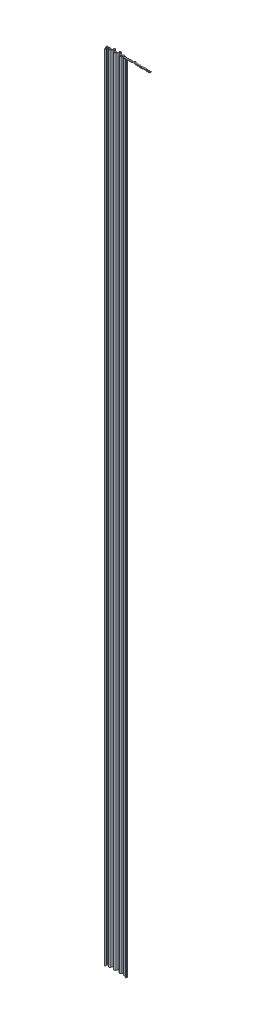
from build123d import *

# Parameters (mm, degrees)
BOSS_EXTRUDE1_DEPTH    = 2.54
SKETCH1_R              = 3.81
BOSS_EXTRUDE1_2_DEPTH  = 2.54
BOSS_EXTRUDE1_3_DEPTH  = 2.54
SKETCH1_R_2            = 3.745422698
BOSS_EXTRUDE1_4_DEPTH  = 2.54
BOSS_EXTRUDE1_5_DEPTH  = 2.54
BOSS_EXTRUDE1_6_DEPTH  = 2.54
SKETCH1_R_3            = 3.74542269
BOSS_EXTRUDE1_7_DEPTH  = 2.54
BOSS_EXTRUDE1_8_DEPTH  = 2.54
BOSS_EXTRUDE1_9_DEPTH  = 2.54
BOSS_EXTRUDE1_10_DEPTH = 2.54
BOSS_EXTRUDE1_11_DEPTH = 2.54
BOSS_EXTRUDE1_12_DEPTH = 2.54
SKETCH1_R_4            = 3.80999999
BOSS_EXTRUDE1_13_DEPTH = 2.54
BOSS_EXTRUDE1_14_DEPTH = 2.54
SKETCH1_R_5            = 3.809999995
BOSS_EXTRUDE1_15_DEPTH = 2.54
BOSS_EXTRUDE1_16_DEPTH = 2.54
BOSS_EXTRUDE1_17_DEPTH = 2.54
BOSS_EXTRUDE1_18_DEPTH = 2.54
BOSS_EXTRUDE1_19_DEPTH = 2.54
BOSS_EXTRUDE1_20_DEPTH = 2.54
BOSS_EXTRUDE1_21_DEPTH = 2.54
BOSS_EXTRUDE1_22_DEPTH = 2.54
BOSS_EXTRUDE1_23_DEPTH = 2.54
BOSS_EXTRUDE2_DEPTH    = 3657.6
SKETCH4_W              = 101.61524
SKETCH4_H              = 83.613834965
CUT_EXTRUDE1_DEPTH     = 3657.6
CUT_EXTRUDE2_DEPTH     = 3658.6
BOSS_EXTRUDE3_DEPTH    = 3657.6
FILLET1_R              = 0.508
FILLET2_R              = 0.508


with BuildPart() as part:
    # Sketch1 → Boss-Extrude1 (new body)
    with BuildSketch(Plane(origin=(0, 0, 0), x_dir=(1, 0, 0), z_dir=(0, 1, 0))):
        with BuildLine():
            ThreePointArc((0, 6.35), (3.81, 10.16), (0, 13.97))
            Line((0, 13.97), (0, 6.35))
        make_face()
    extrude(amount=BOSS_EXTRUDE1_DEPTH)


with BuildPart() as body_2:
    # Sketch1 → Boss-Extrude1 2 (new body)
    with BuildSketch(Plane(origin=(0, 0, 0), x_dir=(1, 0, 0), z_dir=(0, 1, 0))):
        with Locations(Location((101.6, 10.16, 0), (0, 0, 270))):  # turned: the seam where the file's is
            Circle(SKETCH1_R)
    extrude(amount=BOSS_EXTRUDE1_2_DEPTH)


with BuildPart() as body_3:
    # Sketch1 → Boss-Extrude1 3 (new body)
    with BuildSketch(Plane(origin=(0, 0, 0), x_dir=(1, 0, 0), z_dir=(0, 1, 0))):
        with BuildLine():
            Line((203.2, 6.35), (203.2, 13.97))
            ThreePointArc((203.2, 13.97), (199.39, 10.16), (203.2, 6.35))
        make_face()
    extrude(amount=BOSS_EXTRUDE1_3_DEPTH)


with BuildPart() as body_4:
    # Sketch1 → Boss-Extrude1 4 (new body)
    with BuildSketch(Plane(origin=(0, 0, 0), x_dir=(1, 0, 0), z_dir=(0, 1, 0))):
        with Locations(Location((8.458503581, 10.421666317, 0), (0, 0, 270))):  # turned: the seam where the file's is
            Circle(SKETCH1_R_2)
    extrude(amount=BOSS_EXTRUDE1_4_DEPTH)


with BuildPart() as body_5:
    # Sketch1 → Boss-Extrude1 5 (new body)
    with BuildSketch(Plane(origin=(0, 0, 0), x_dir=(1, 0, 0), z_dir=(0, 1, 0))):
        with Locations(Location((178.844606251, 10.764698431, 0), (0, 0, 270))):  # turned: the seam where the file's is
            Circle(SKETCH1_R_2)
    extrude(amount=BOSS_EXTRUDE1_5_DEPTH)


with BuildPart() as body_6:
    # Sketch1 → Boss-Extrude1 6 (new body)
    with BuildSketch(Plane(origin=(0, 0, 0), x_dir=(1, 0, 0), z_dir=(0, 1, 0))):
        with Locations(Location((93.751937651, 9.11257087, 0), (0, 0, 270))):  # turned: the seam where the file's is
            Circle(SKETCH1_R_2)
    extrude(amount=BOSS_EXTRUDE1_6_DEPTH)


with BuildPart() as body_7:
    # Sketch1 → Boss-Extrude1 7 (new body)
    with BuildSketch(Plane(origin=(0, 0, 0), x_dir=(1, 0, 0), z_dir=(0, 1, 0))):
        with Locations(Location((109.996304942, 10.288280903, 0), (0, 0, 270))):  # turned: the seam where the file's is
            Circle(SKETCH1_R_3)
    extrude(amount=BOSS_EXTRUDE1_7_DEPTH)


with BuildPart() as body_8:
    # Sketch1 → Boss-Extrude1 8 (new body)
    with BuildSketch(Plane(origin=(0, 0, 0), x_dir=(1, 0, 0), z_dir=(0, 1, 0))):
        with Locations(Location((195.331534167, 9.156326282, 0), (0, 0, 270))):  # turned: the seam where the file's is
            Circle(SKETCH1_R_2)
    extrude(amount=BOSS_EXTRUDE1_8_DEPTH)


with BuildPart() as body_9:
    # Sketch1 → Boss-Extrude1 9 (new body)
    with BuildSketch(Plane(origin=(0, 0, 0), x_dir=(1, 0, 0), z_dir=(0, 1, 0))):
        with Locations(Location((29.013577586, 18.223525836, 0), (0, 0, 270))):  # turned: the seam where the file's is
            Circle(SKETCH1_R_2)
    extrude(amount=BOSS_EXTRUDE1_9_DEPTH)


with BuildPart() as body_10:
    # Sketch1 → Boss-Extrude1 10 (new body)
    with BuildSketch(Plane(origin=(0, 0, 0), x_dir=(1, 0, 0), z_dir=(0, 1, 0))):
        with Locations(Location((53.950418443, 19.818395657, 0), (0, 0, 270))):  # turned: the seam where the file's is
            Circle(SKETCH1_R_2)
    extrude(amount=BOSS_EXTRUDE1_10_DEPTH)


with BuildPart() as body_11:
    # Sketch1 → Boss-Extrude1 11 (new body)
    with BuildSketch(Plane(origin=(0, 0, 0), x_dir=(1, 0, 0), z_dir=(0, 1, 0))):
        with Locations(Location((16.917007163, 10.16, 0), (0, 0, 270))):  # turned: the seam where the file's is
            Circle(SKETCH1_R)
    extrude(amount=BOSS_EXTRUDE1_11_DEPTH)


with BuildPart() as body_12:
    # Sketch1 → Boss-Extrude1 12 (new body)
    with BuildSketch(Plane(origin=(0, 0, 0), x_dir=(1, 0, 0), z_dir=(0, 1, 0))):
        with Locations(Location((85.903875302, 10.16, 0), (0, 0, 270))):  # turned: the seam where the file's is
            Circle(SKETCH1_R)
    extrude(amount=BOSS_EXTRUDE1_12_DEPTH)


with BuildPart() as body_13:
    # Sketch1 → Boss-Extrude1 13 (new body)
    with BuildSketch(Plane(origin=(0, 0, 0), x_dir=(1, 0, 0), z_dir=(0, 1, 0))):
        with Locations(Location((118.392609883, 10.16, 0), (0, 0, 270))):  # turned: the seam where the file's is
            Circle(SKETCH1_R_4)
    extrude(amount=BOSS_EXTRUDE1_13_DEPTH)


with BuildPart() as body_14:
    # Sketch1 → Boss-Extrude1 14 (new body)
    with BuildSketch(Plane(origin=(0, 0, 0), x_dir=(1, 0, 0), z_dir=(0, 1, 0))):
        with Locations(Location((41.110148009, 10.16, 0), (0, 0, 270))):  # turned: the seam where the file's is
            Circle(SKETCH1_R)
    extrude(amount=BOSS_EXTRUDE1_14_DEPTH)


with BuildPart() as body_15:
    # Sketch1 → Boss-Extrude1 15 (new body)
    with BuildSketch(Plane(origin=(0, 0, 0), x_dir=(1, 0, 0), z_dir=(0, 1, 0))):
        with Locations(Location((187.463068334, 10.16, 0), (0, 0, 270))):  # turned: the seam where the file's is
            Circle(SKETCH1_R_5)
    extrude(amount=BOSS_EXTRUDE1_15_DEPTH)


with BuildPart() as body_16:
    # Sketch1 → Boss-Extrude1 16 (new body)
    with BuildSketch(Plane(origin=(0, 0, 0), x_dir=(1, 0, 0), z_dir=(0, 1, 0))):
        with Locations(Location((76.34728209, 12.776527129, 0), (0, 0, 270))):  # turned: the seam where the file's is
            Circle(SKETCH1_R_2)
    extrude(amount=BOSS_EXTRUDE1_16_DEPTH)


with BuildPart() as body_17:
    # Sketch1 → Boss-Extrude1 17 (new body)
    with BuildSketch(Plane(origin=(0, 0, 0), x_dir=(1, 0, 0), z_dir=(0, 1, 0))):
        with Locations(Location((128.306786724, 13.543367696, 0), (0, 0, 270))):  # turned: the seam where the file's is
            Circle(SKETCH1_R_2)
    extrude(amount=BOSS_EXTRUDE1_17_DEPTH)


with BuildPart() as body_18:
    # Sketch1 → Boss-Extrude1 18 (new body)
    with BuildSketch(Plane(origin=(0, 0, 0), x_dir=(1, 0, 0), z_dir=(0, 1, 0))):
        with Locations(Location((66.790688878, 10.16, 0), (0, 0, 270))):  # turned: the seam where the file's is
            Circle(SKETCH1_R)
    extrude(amount=BOSS_EXTRUDE1_18_DEPTH)


with BuildPart() as body_19:
    # Sketch1 → Boss-Extrude1 19 (new body)
    with BuildSketch(Plane(origin=(0, 0, 0), x_dir=(1, 0, 0), z_dir=(0, 1, 0))):
        with Locations(Location((138.220963565, 10.16, 0), (0, 0, 270))):  # turned: the seam where the file's is
            Circle(SKETCH1_R)
    extrude(amount=BOSS_EXTRUDE1_19_DEPTH)


with BuildPart() as body_20:
    # Sketch1 → Boss-Extrude1 20 (new body)
    with BuildSketch(Plane(origin=(0, 0, 0), x_dir=(1, 0, 0), z_dir=(0, 1, 0))):
        with BuildLine():
            ThreePointArc((167.734361196, 13.042207075), (170.706470879, 6.380398665), (171.917798642, 13.573854879))
            add(Edge.make_bspline(
                [(167.734361196, 13.042207075), (169.179026311, 13.19298533), (170.576286763, 13.380317923), (171.917798642, 13.573854879)],
                knots=[0.810980003, 0.810980003, 0.810980003, 0.810980003, 0.825646316, 0.825646316, 0.825646316, 0.825646316], degree=3))
        make_face()
    extrude(amount=BOSS_EXTRUDE1_20_DEPTH)


with BuildPart() as body_21:
    # Sketch1 → Boss-Extrude1 21 (new body)
    with BuildSketch(Plane(origin=(0, 0, 0), x_dir=(1, 0, 0), z_dir=(0, 1, 0))):
        with Locations(Location((146.444769576, 9.918355753, 0), (0, 0, 270))):  # turned: the seam where the file's is
            Circle(SKETCH1_R_2)
    extrude(amount=BOSS_EXTRUDE1_21_DEPTH)


with BuildPart() as body_22:
    # Sketch1 → Boss-Extrude1 22 (new body)
    with BuildSketch(Plane(origin=(0, 0, 0), x_dir=(1, 0, 0), z_dir=(0, 1, 0))):
        with Locations(Location((162.447359877, 8.964003594, 0), (0, 0, 270))):  # turned: the seam where the file's is
            Circle(SKETCH1_R_2)
    extrude(amount=BOSS_EXTRUDE1_22_DEPTH)


with BuildPart() as body_23:
    # Sketch1 → Boss-Extrude1 23 (new body)
    with BuildSketch(Plane(origin=(0, 0, 0), x_dir=(1, 0, 0), z_dir=(0, 1, 0))):
        with Locations(Location((154.668575586, 10.16, 0), (0, 0, 270))):  # turned: the seam where the file's is
            Circle(SKETCH1_R)
    extrude(amount=BOSS_EXTRUDE1_23_DEPTH)


with BuildPart() as body_24:
    # Sketch3 → Boss-Extrude2 (new body)
    with BuildSketch(Plane.XZ):
        with BuildLine():
            Line((4.834245736, -7.905754192), (6.445210891, -11.360480116))
            ThreePointArc((6.445210891, -11.360480116), (8.458503581, -12.643089015), (10.471796271, -11.360480116))
            Line((10.471796271, -11.360480116), (12.082761427, -7.905754192))
            ThreePointArc((12.082761427, -7.905754192), (16.917007163, -4.826), (21.751252899, -7.905754192))
            Line((21.751252899, -7.905754192), (27.000284896, -19.162339635))
            ThreePointArc((27.000284896, -19.162339635), (29.013577586, -20.444948534), (31.026870276, -19.162339635))
            Line((31.026870276, -19.162339635), (36.275902273, -7.905754192))
            ThreePointArc((36.275902273, -7.905754192), (41.110148009, -4.826), (45.944393745, -7.905754192))
            Line((45.944393745, -7.905754192), (51.937125753, -20.757209457))
            ThreePointArc((51.937125753, -20.757209457), (53.950418443, -22.039818356), (55.963711133, -20.757209457))
            Line((55.963711133, -20.757209457), (61.956443142, -7.905754192))
            ThreePointArc((61.956443142, -7.905754192), (66.790688878, -4.826), (71.624934614, -7.905754192))
            Line((71.624934614, -7.905754192), (74.3339894, -13.715340929))
            ThreePointArc((74.3339894, -13.715340929), (76.34728209, -14.997949828), (78.36057478, -13.715340929))
            Line((78.36057478, -13.715340929), (81.069629566, -7.905754192))
            ThreePointArc((81.069629566, -7.905754192), (85.903875302, -4.826), (90.738121038, -7.905754192))
            Line((90.738121038, -7.905754192), (91.738644961, -10.051384669))
            ThreePointArc((91.738644961, -10.051384669), (93.751937651, -11.333993568), (95.765230341, -10.051384669))
            Line((95.765230341, -10.051384669), (96.765754264, -7.905754192))
            ThreePointArc((96.765754264, -7.905754192), (101.6, -4.826), (106.434245736, -7.905754192))
            Line((106.434245736, -7.905754192), (107.983012252, -11.227094703))
            ThreePointArc((107.983012252, -11.227094703), (109.996304942, -12.509703602), (112.009597624, -11.227094699))
            Line((112.009597624, -11.227094699), (113.558364147, -7.905754192))
            ThreePointArc((113.558364147, -7.905754192), (118.392609883, -4.82600001), (123.22685561, -7.905754196))
            Line((123.22685561, -7.905754196), (126.293494034, -14.482181495))
            ThreePointArc((126.293494034, -14.482181495), (128.306786724, -15.764790394), (130.320079414, -14.482181495))
            Line((130.320079414, -14.482181495), (133.386717829, -7.905754192))
            ThreePointArc((133.386717829, -7.905754192), (138.220963565, -4.826), (143.055209301, -7.905754192))
            Line((143.055209301, -7.905754192), (144.431476886, -10.857169552))
            ThreePointArc((144.431476886, -10.857169552), (146.444769576, -12.139778451), (148.458062265, -10.857169552))
            Line((148.458062265, -10.857169552), (149.83432985, -7.905754192))
            ThreePointArc((149.83432985, -7.905754192), (154.668575586, -4.826), (159.502821322, -7.905754192))
            Line((159.502821322, -7.905754192), (160.434067187, -9.902817393))
            ThreePointArc((160.434067187, -9.902817393), (162.447359877, -11.185426292), (164.460652567, -9.902817393))
            Line((164.460652567, -9.902817393), (165.391898432, -7.905754192))
            ThreePointArc((165.391898432, -7.905754192), (170.226144168, -4.826), (175.060389904, -7.905754192))
            Line((175.060389904, -7.905754192), (176.831313561, -11.70351223))
            ThreePointArc((176.831313561, -11.70351223), (178.844606251, -12.986121129), (180.857898941, -11.70351223))
            Line((180.857898941, -11.70351223), (182.628822598, -7.905754192))
            ThreePointArc((182.628822598, -7.905754192), (187.463068334, -4.826000005), (192.297314065, -7.905754194))
            Line((192.297314065, -7.905754194), (193.318241477, -10.095140082))
            ThreePointArc((193.318241477, -10.095140082), (195.331534167, -11.377748981), (197.344826856, -10.095140081))
            Line((197.344826856, -10.095140081), (198.365754264, -7.905754192))
            ThreePointArc((198.365754264, -7.905754192), (200.334043889, -5.661350028), (203.2, -4.826))
            Line((203.2, -4.826), (203.2, -6.35))
            ThreePointArc((203.2, -6.35), (201.152888492, -6.946678591), (199.746967331, -8.549824423))
            Line((199.746967331, -8.549824423), (198.726039924, -10.739210313))
            ThreePointArc((198.726039924, -10.739210313), (195.331534167, -12.901748981), (191.93702841, -10.739210313))
            Line((191.93702841, -10.739210313), (190.916101003, -8.549824423))
            ThreePointArc((190.916101003, -8.549824423), (187.463068334, -6.35), (184.010035665, -8.549824423))
            Line((184.010035665, -8.549824423), (182.239112008, -12.347582461))
            ThreePointArc((182.239112008, -12.347582461), (178.844606251, -14.510121129), (175.450100493, -12.347582461))
            Line((175.450100493, -12.347582461), (173.679176836, -8.549824423))
            ThreePointArc((173.679176836, -8.549824423), (170.226144168, -6.35), (166.773111499, -8.549824423))
            Line((166.773111499, -8.549824423), (165.841865634, -10.546887624))
            ThreePointArc((165.841865634, -10.546887624), (162.447359877, -12.709426292), (159.05285412, -10.546887624))
            Line((159.05285412, -10.546887624), (158.121608255, -8.549824423))
            ThreePointArc((158.121608255, -8.549824423), (154.668575586, -6.35), (151.215542918, -8.549824423))
            Line((151.215542918, -8.549824423), (149.839275333, -11.501239783))
            ThreePointArc((149.839275333, -11.501239783), (146.444769576, -13.663778451), (143.050263818, -11.501239783))
            Line((143.050263818, -11.501239783), (141.673996233, -8.549824423))
            ThreePointArc((141.673996233, -8.549824423), (138.220963565, -6.35), (134.767930896, -8.549824423))
            Line((134.767930896, -8.549824423), (131.701292481, -15.126251726))
            ThreePointArc((131.701292481, -15.126251726), (128.306786724, -17.288790394), (124.912280967, -15.126251726))
            Line((124.912280967, -15.126251726), (121.845642552, -8.549824423))
            ThreePointArc((121.845642552, -8.549824423), (118.392609883, -6.35), (114.939577215, -8.549824423))
            Line((114.939577215, -8.549824423), (113.390810699, -11.871164934))
            ThreePointArc((113.390810699, -11.871164934), (109.996304942, -14.033703602), (106.601799184, -11.871164934))
            Line((106.601799184, -11.871164934), (105.053032669, -8.549824423))
            ThreePointArc((105.053032669, -8.549824423), (101.6, -6.35), (98.146967331, -8.549824423))
            Line((98.146967331, -8.549824423), (97.146443408, -10.6954549))
            ThreePointArc((97.146443408, -10.6954549), (93.751937651, -12.857993568), (90.357431894, -10.6954549))
            Line((90.357431894, -10.6954549), (89.356907971, -8.549824423))
            ThreePointArc((89.356907971, -8.549824423), (85.903875302, -6.35), (82.450842633, -8.549824423))
            Line((82.450842633, -8.549824423), (79.741787847, -14.35941116))
            ThreePointArc((79.741787847, -14.35941116), (76.34728209, -16.521949828), (72.952776332, -14.35941116))
            Line((72.952776332, -14.35941116), (70.243721546, -8.549824423))
            ThreePointArc((70.243721546, -8.549824423), (66.790688878, -6.35), (63.337656209, -8.549824423))
            Line((63.337656209, -8.549824423), (57.344924201, -21.401279688))
            ThreePointArc((57.344924201, -21.401279688), (53.950418443, -23.563818356), (50.555912686, -21.401279688))
            Line((50.555912686, -21.401279688), (44.563180677, -8.549824423))
            ThreePointArc((44.563180677, -8.549824423), (41.110148009, -6.35), (37.65711534, -8.549824423))
            Line((37.65711534, -8.549824423), (32.408083343, -19.806409866))
            ThreePointArc((32.408083343, -19.806409866), (29.013577586, -21.968948534), (25.619071828, -19.806409866))
            Line((25.619071828, -19.806409866), (20.370039831, -8.549824423))
            ThreePointArc((20.370039831, -8.549824423), (16.917007163, -6.35), (13.463974494, -8.549824423))
            Line((13.463974494, -8.549824423), (11.853009339, -12.004550347))
            ThreePointArc((11.853009339, -12.004550347), (8.458503581, -14.167089015), (5.063997824, -12.004550347))
            Line((5.063997824, -12.004550347), (3.453032669, -8.549824423))
            ThreePointArc((3.453032669, -8.549824423), (2.047111508, -6.946678591), (0, -6.35))
            Line((0, -6.35), (0, -4.826))
            ThreePointArc((0, -4.826), (2.865956111, -5.661350028), (4.834245736, -7.905754192))
        make_face()
    extrude(amount=BOSS_EXTRUDE2_DEPTH)

    # Sketch4 → Cut-Extrude1 (cut)
    with BuildSketch(Plane(origin=(0, 0, 0), x_dir=(1, 0, 0), z_dir=(0, 1, 0))):
        with Locations((152.39238, 6.221605614)):
            Rectangle(SKETCH4_W, SKETCH4_H)
    extrude(amount=-CUT_EXTRUDE1_DEPTH, mode=Mode.SUBTRACT)

    # Sketch5 → Cut-Extrude2 (cut, through all)
    with BuildSketch(Plane(origin=(0, 0, 0), x_dir=(1, 0, 0), z_dir=(0, 1, 0))):
        Polygon((0, 5.588), (0.36620361, 4.581863852), (0, 4.581863852), align=None)
        Polygon((101.58476, 5.58803048), (101.58476, 1.526438119), (100.106461277, 1.526438119), align=None)
    extrude(amount=-CUT_EXTRUDE2_DEPTH, mode=Mode.SUBTRACT)

    # Sketch6 → Boss-Extrude3 (add, through all)
    with BuildSketch(Plane(origin=(0, 0, 0), x_dir=(1, 0, 0), z_dir=(0, 1, 0))):
        with BuildLine():
            ThreePointArc((3.872542856, 6.491898607), (2.233375202, 5.316076879), (0.274767793, 4.833081692))
            Line((0.274767793, 4.833081692), (0.346681648, 4.6355))
            Line((0.346681648, 4.6355), (2.794, 4.6355))
            ThreePointArc((2.794, 4.6355), (4.0005, 3.429), (2.794, 2.2225))
            Line((2.794, 2.2225), (1.769066214, 2.2225))
            ThreePointArc((1.769066214, 2.2225), (1.456969285, 2.060032622), (1.411043325, 1.711190325))
            Line((1.411043325, 1.711190325), (1.63748848, 1.089037376))
            ThreePointArc((1.63748848, 1.089037376), (1.726414147, 0.949629263), (1.866026726, 0.861024951))
            ThreePointArc((1.866026726, 0.861024951), (5.310342574, 2.368976273), (3.98321595, 5.886925075))
            ThreePointArc((3.98321595, 5.886925075), (3.774372758, 6.161329529), (3.872542856, 6.491898607))
        make_face()
        with BuildLine():
            Line((99.93203152, 1.089037376), (100.158476675, 1.711190325))
            ThreePointArc((100.158476675, 1.711190325), (100.112550715, 2.060032622), (99.800453786, 2.2225))
            Line((99.800453786, 2.2225), (98.77552, 2.2225))
            ThreePointArc((98.77552, 2.2225), (97.56902, 3.429), (98.77552, 4.6355))
            Line((98.77552, 4.6355), (101.238067258, 4.6355))
            Line((101.238067258, 4.6355), (101.310269688, 4.833874547))
            ThreePointArc((101.310269688, 4.833874547), (99.353966951, 5.321933078), (97.7185903, 6.501282364))
            ThreePointArc((97.7185903, 6.501282364), (97.815783174, 6.16952974), (97.604714903, 5.895747996))
            ThreePointArc((97.604714903, 5.895747996), (96.255232148, 2.378390942), (99.703493274, 0.861024951))
            ThreePointArc((99.703493274, 0.861024951), (99.843105853, 0.949629263), (99.93203152, 1.089037376))
        make_face()
    extrude(amount=-BOSS_EXTRUDE3_DEPTH)

    # Fillet1
    fillet1_edges = [body_24.edges().sort_by_distance(p)[0] for p in [
        (101.238067258, -1828.8, -4.6355),
    ]]
    fillet(fillet1_edges, radius=FILLET1_R)

    # Fillet2
    fillet2_edges = [body_24.edges().sort_by_distance(p)[0] for p in [
        (0.346681648, -1828.8, -4.6355),
    ]]
    fillet(fillet2_edges, radius=FILLET2_R)


solid = Compound([part.part, body_2.part, body_3.part, body_4.part, body_5.part, body_6.part, body_7.part, body_8.part, body_9.part, body_10.part, body_11.part, body_12.part, body_13.part, body_14.part, body_15.part, body_16.part, body_17.part, body_18.part, body_19.part, body_20.part, body_21.part, body_22.part, body_23.part, body_24.part])
